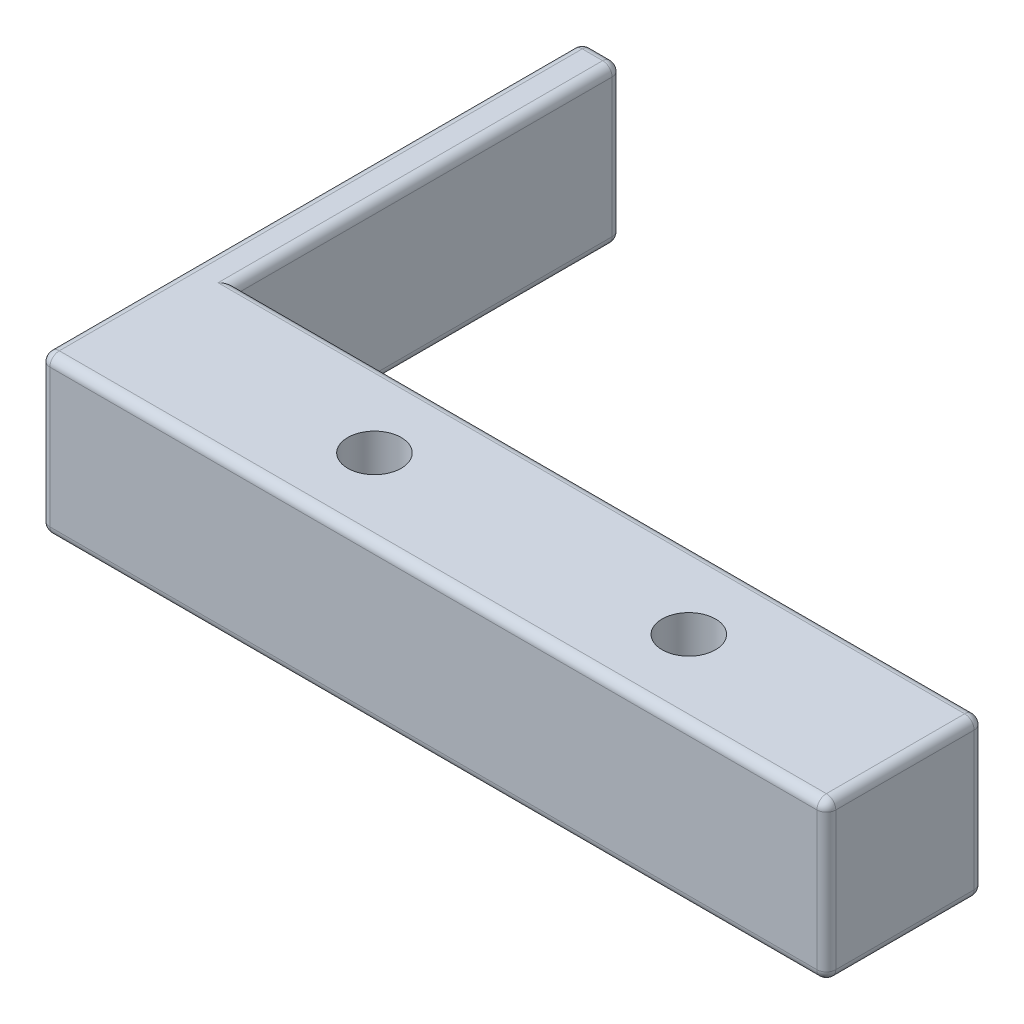
from build123d import *

# Parameters (mm, degrees)
SKETCH1_W           = 60.325
SKETCH1_H           = 12.7
SKETCH1_R           = 2.159
BOSS_EXTRUDE1_DEPTH = 12.7
SKETCH4_W           = 43.775259309
SKETCH4_H           = 12.7
BOSS_EXTRUDE2_DEPTH = 3.175
SKETCH5_R           = 3.556
CUT_EXTRUDE1_DEPTH  = 3.81
FILLET5_R           = 0.762


with BuildPart() as part:
    # Sketch1 → Boss-Extrude1 (new body)
    with BuildSketch(Plane(origin=(0, 0, 0), x_dir=(1, 0, 0), z_dir=(0, 1, 0))):
        with Locations((30.1625, 6.35)):
            Rectangle(SKETCH1_W, SKETCH1_H)
        with Locations((17.4625, 6.35)):
            Circle(SKETCH1_R, mode=Mode.SUBTRACT)
        with Locations((42.8625, 6.35)):
            Circle(SKETCH1_R, mode=Mode.SUBTRACT)
    extrude(amount=BOSS_EXTRUDE1_DEPTH)

    # Sketch4 → Boss-Extrude2 (add)
    with BuildSketch(Plane.ZY):
        with Locations((-21.887629655, 6.35)):
            Rectangle(SKETCH4_W, SKETCH4_H)
    extrude(amount=BOSS_EXTRUDE2_DEPTH)

    # Sketch5 → Cut-Extrude1 (cut)
    with BuildSketch(Plane.XZ):
        with Locations((42.8625, -6.35)):
            Circle(SKETCH5_R)
        with Locations((17.4625, -6.35)):
            Circle(SKETCH5_R)
    extrude(amount=-CUT_EXTRUDE1_DEPTH, mode=Mode.SUBTRACT)

    # Fillet5
    fillet5_edges = [part.edges().sort_by_distance(p)[0] for p in [
        (60.325, 12.7, -6.35),
        (30.1625, 12.7, -12.7),
        (0, 6.35, -43.775259309),
        (-1.5875, 12.7, -43.775259309),
        (0, 0, -28.237629654),
        (-1.5875, 0, -43.775259309),
        (0, 12.7, -28.237629654),
        (-3.175, 6.35, -43.775259309),
        (-3.175, 0, -21.887629654),
        (-3.175, 6.35, 0),
        (-3.175, 12.7, -21.887629654),
        (39.3065, 0, -6.35),
        (13.9065, 0, -6.35),
        (30.1625, 0, -12.7),
        (60.325, 0, -6.35),
        (28.575, 0, 0),
        (28.575, 12.7, 0),
        (60.325, 6.35, -12.7),
        (60.325, 6.35, 0),
    ]]
    fillet(fillet5_edges, radius=FILLET5_R)


solid = part.part
